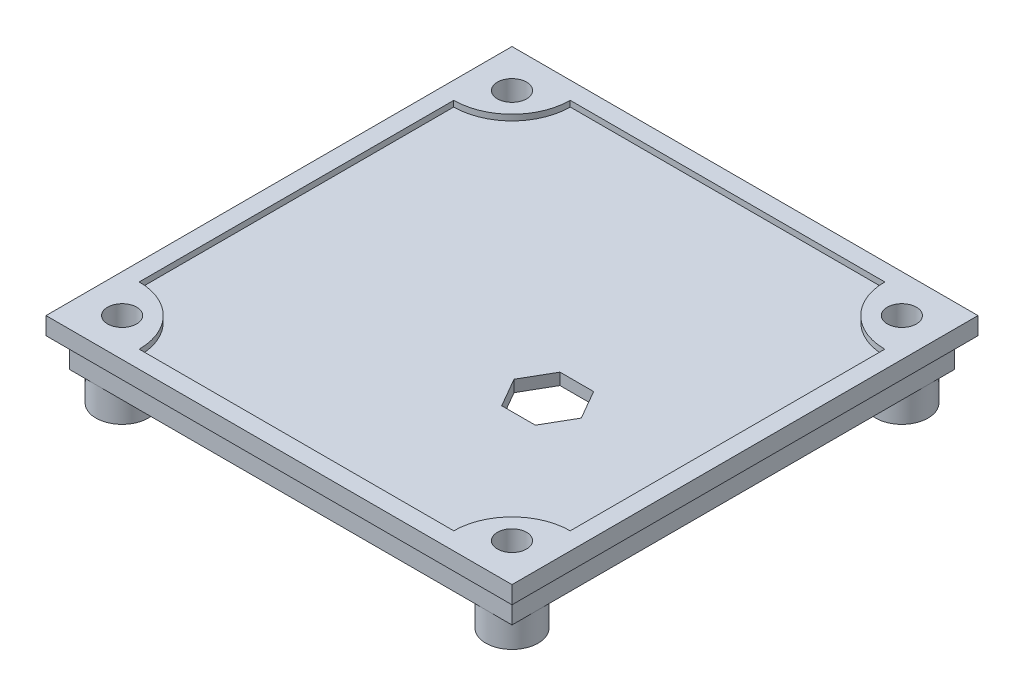
from build123d import *

# Parameters (mm, degrees)
SKETCH2_W           = 80
SKETCH2_H           = 80
BOSS_EXTRUDE1_DEPTH = 3
CUT_EXTRUDE1_DEPTH  = 1
SKETCH5_W           = 76
SKETCH5_H           = 76
BOSS_EXTRUDE2_DEPTH = 5
SKETCH6_W           = 74
SKETCH6_H           = 74
CUT_EXTRUDE2_DEPTH  = 5
SKETCH7_R           = 4.5
BOSS_EXTRUDE3_DEPTH = 10
SKETCH4_R           = 2.5
CUT_EXTRUDE8_DEPTH  = 13
SKETCH9_R           = 3
SKETCH9_R_2         = 2
BOSS_EXTRUDE4_DEPTH = 5
BOSS_EXTRUDE5_DEPTH = 5
CUT_EXTRUDE9_DEPTH  = 10


with BuildPart() as part:
    # Sketch2 → Boss-Extrude1 (new body)
    with BuildSketch(Plane(origin=(0, 0, 0), x_dir=(1, 0, 0), z_dir=(0, 1, 0))):
        Rectangle(SKETCH2_W, SKETCH2_H)
    extrude(amount=-BOSS_EXTRUDE1_DEPTH)

    # Sketch3 → Cut-Extrude1 (cut)
    with BuildSketch(Plane(origin=(0, 0, 0), x_dir=(1, 0, 0), z_dir=(0, 1, 0))):
        with BuildLine():
            Line((-27, 37), (27, 37))
            ThreePointArc((27, 37), (29.928932188, 29.928932188), (37, 27))
            Line((37, 27), (37, -27))
            ThreePointArc((37, -27), (29.928932188, -29.928932188), (27, -37))
            Line((27, -37), (-27, -37))
            ThreePointArc((-27, -37), (-29.928932188, -29.928932188), (-37, -27))
            Line((-37, -27), (-37, 27))
            ThreePointArc((-37, 27), (-29.928932188, 29.928932188), (-27, 37))
        make_face()
    extrude(amount=-CUT_EXTRUDE1_DEPTH, mode=Mode.SUBTRACT)

    # Sketch5 → Boss-Extrude2 (add)
    with BuildSketch(Plane.XZ.offset(3)):
        Rectangle(SKETCH5_W, SKETCH5_H)
    extrude(amount=BOSS_EXTRUDE2_DEPTH)

    # Sketch6 → Cut-Extrude2 (cut)
    with BuildSketch(Plane.XZ.offset(8)):
        Rectangle(SKETCH6_W, SKETCH6_H)
    extrude(amount=-CUT_EXTRUDE2_DEPTH, mode=Mode.SUBTRACT)

    # Sketch7 → Boss-Extrude3 (add)
    with BuildSketch(Plane.XZ.offset(3)):
        with Locations((-33.464466094, 33.46446609)):
            Circle(SKETCH7_R)
        with Locations((33.46446609, 33.46446609)):
            Circle(SKETCH7_R)
        with Locations((-33.464466094, -33.464466094)):
            Circle(SKETCH7_R)
        with Locations((33.46446609, -33.464466094)):
            Circle(SKETCH7_R)
    extrude(amount=BOSS_EXTRUDE3_DEPTH)

    # Sketch4 → Cut-Extrude8 (cut)
    with BuildSketch(Plane(origin=(0, 0, 0), x_dir=(1, 0, 0), z_dir=(0, 1, 0))):
        with Locations((33.46446609, 33.464466094)):
            Circle(SKETCH4_R)
        with Locations((-33.464466094, 33.464466094)):
            Circle(SKETCH4_R)
        with Locations((-33.464466094, -33.46446609)):
            Circle(SKETCH4_R)
        with Locations((33.46446609, -33.46446609)):
            Circle(SKETCH4_R)
    extrude(amount=-CUT_EXTRUDE8_DEPTH, mode=Mode.SUBTRACT)

    # Sketch9 → Boss-Extrude4 (add)
    with BuildSketch(Plane.XZ.offset(3)):
        with Locations((-7, 24)):
            Circle(SKETCH9_R)
        with Locations((-7, 24)):
            Circle(SKETCH9_R_2, mode=Mode.SUBTRACT)
    extrude(amount=BOSS_EXTRUDE4_DEPTH)

    # Sketch10 → Boss-Extrude5 (add)
    with BuildSketch(Plane.XZ.offset(3)):
        with BuildLine():
            Line((-8.5, -10), (-8.5, -17))
            ThreePointArc((-8.5, -17), (-9, -17.5), (-9.5, -17))
            Line((-9.5, -17), (-9.5, -10))
            ThreePointArc((-9.5, -10), (-9, -9.5), (-8.5, -10))
        make_face()
        with BuildLine():
            Line((13, -10), (13, -17))
            ThreePointArc((13, -17), (12.5, -17.5), (12, -17))
            Line((12, -17), (12, -10))
            ThreePointArc((12, -10), (12.5, -9.5), (13, -10))
        make_face()
    extrude(amount=BOSS_EXTRUDE5_DEPTH)

    # Sketch11 → Cut-Extrude9 (cut)
    with BuildSketch(Plane(origin=(0, -1, 0), x_dir=(1, 0, 0), z_dir=(0, 1, 0))):
        Polygon((17.300412364, -3.292028925), (11.526909672, -3.292028925), (8.640158326, -8.292028925), (11.526909672, -13.292028925), (17.300412364, -13.292028925), (20.18716371, -8.292028925), align=None)
    extrude(amount=-CUT_EXTRUDE9_DEPTH, mode=Mode.SUBTRACT)


solid = part.part
